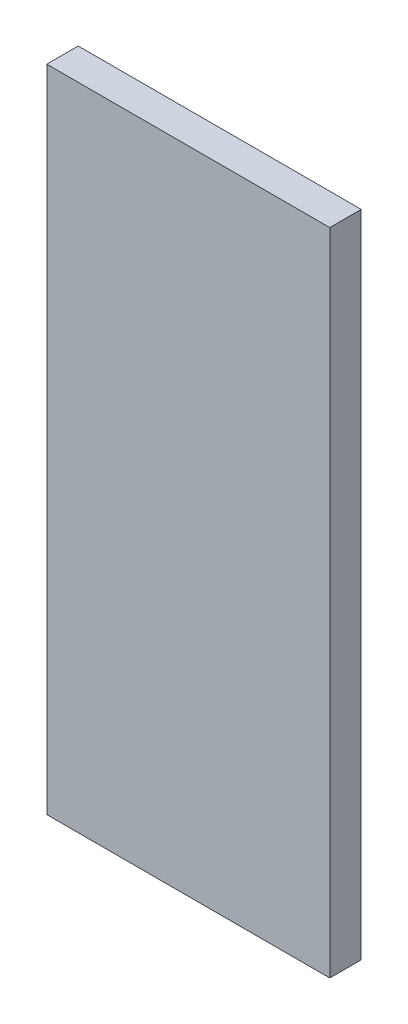
from build123d import *

# Parameters (mm, degrees)
ESQUISSE1_W        = 27
ESQUISSE1_H        = 62
BOSS_EXTRU_1_DEPTH = 3


with BuildPart() as part:
    # Esquisse1 → Boss.-Extru.1 (new body)
    with BuildSketch(Plane.XY):
        Rectangle(ESQUISSE1_W, ESQUISSE1_H)
    extrude(amount=BOSS_EXTRU_1_DEPTH)


solid = part.part
